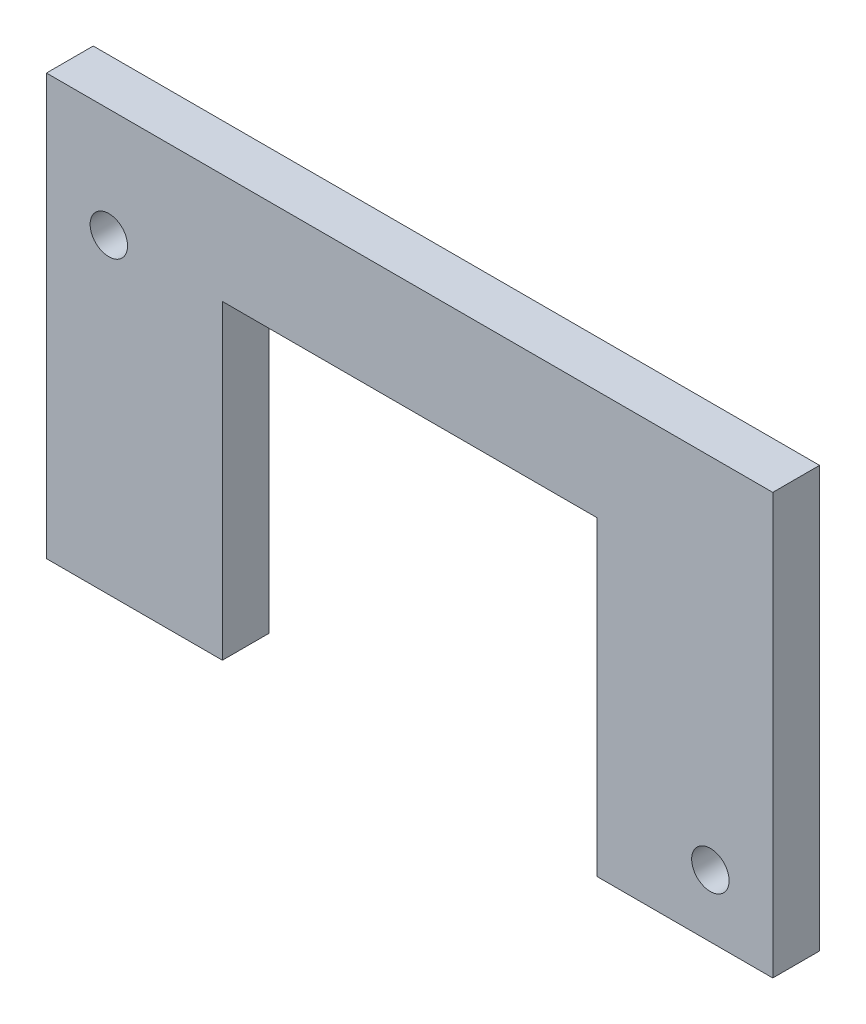
from build123d import *

# Parameters (mm, degrees)
SKETCH1_W           = 36.957
SKETCH1_H           = 21.3995
SKETCH1_R           = 0.9525
BOSS_EXTRUDE1_DEPTH = 2.38125
CUT_EXTRUDE1_REACH  = 4.381
SKETCH2_W           = 19.05
SKETCH2_H           = 15.8115


with BuildPart() as part:
    # Sketch1 → Boss-Extrude1 (new body)
    with BuildSketch(Plane.XY):
        with Locations((16.891, 9.11225)):
            Rectangle(SKETCH1_W, SKETCH1_H)
        with Locations((1.5875, 14.25575)):
            Circle(SKETCH1_R, mode=Mode.SUBTRACT)
        with Locations((32.1945, 1.5875)):
            Circle(SKETCH1_R, mode=Mode.SUBTRACT)
    extrude(amount=BOSS_EXTRUDE1_DEPTH)

    # Sketch2 → Cut-Extrude1 (cut, up to next)
    with BuildSketch(Plane.XY.offset(2.38125), mode=Mode.PRIVATE) as cut_extrude1_sk1:
        with Locations((16.891, 6.31825)):
            Rectangle(SKETCH2_W, SKETCH2_H)
    cut_extrude1_tool1 = extrude(cut_extrude1_sk1.sketch, amount=-CUT_EXTRUDE1_REACH, mode=Mode.PRIVATE) & part.part
    add(cut_extrude1_tool1.solids().sort_by_distance((16.891, 6.31825, 2.38125))[0], mode=Mode.SUBTRACT)


solid = part.part
